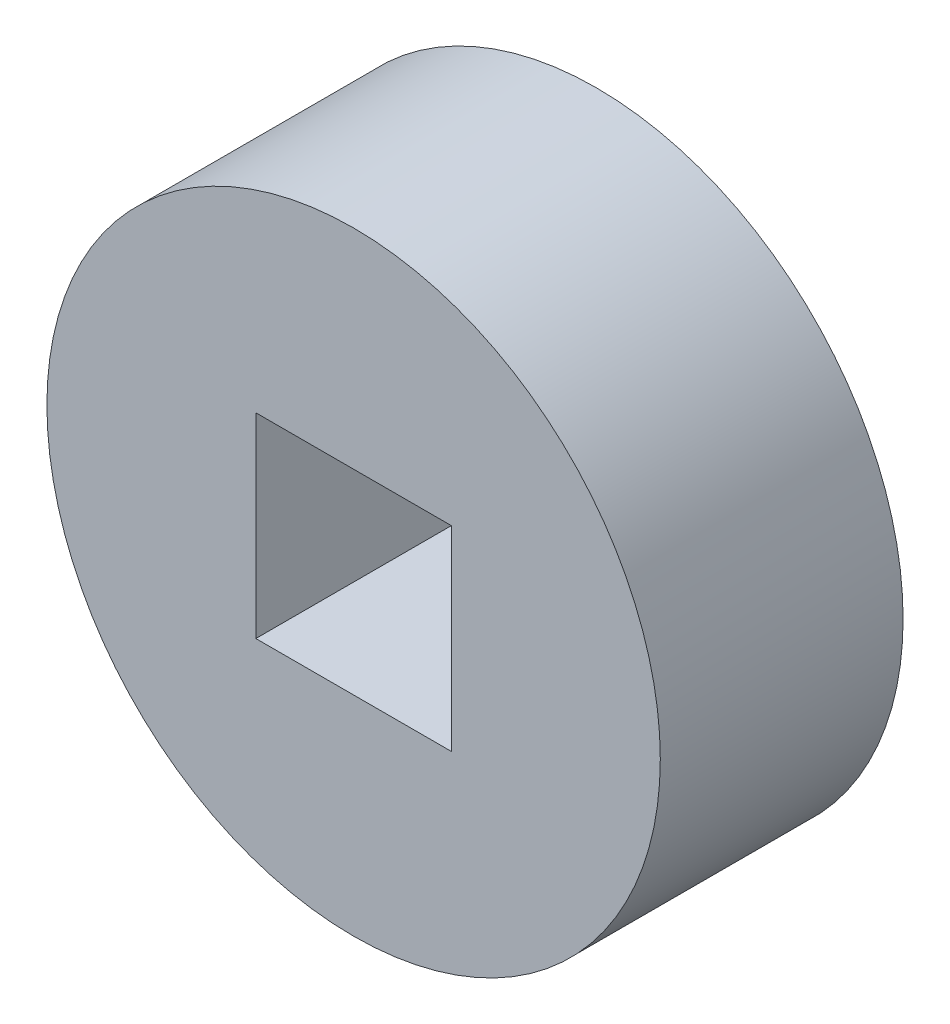
from build123d import *

# Parameters (mm, degrees)
BOSS_EXTRUDE1_START = 8
SKETCH1_R           = 8
BOSS_EXTRUDE1_DEPTH = 6.333
SKETCH3_W           = 5.1
SKETCH3_H           = 5.1
CUT_EXTRUDE4_DEPTH  = 9


with BuildPart() as part:
    # Sketch1 → Boss-Extrude1 (new body)
    with BuildSketch(Plane.XY.offset(BOSS_EXTRUDE1_START)):
        Circle(SKETCH1_R)
    extrude(amount=-BOSS_EXTRUDE1_DEPTH)

    # Sketch3 → Cut-Extrude4 (cut, through all)
    with BuildSketch(Plane.XY):
        Rectangle(SKETCH3_W, SKETCH3_H)
    extrude(amount=CUT_EXTRUDE4_DEPTH, mode=Mode.SUBTRACT)


solid = part.part
